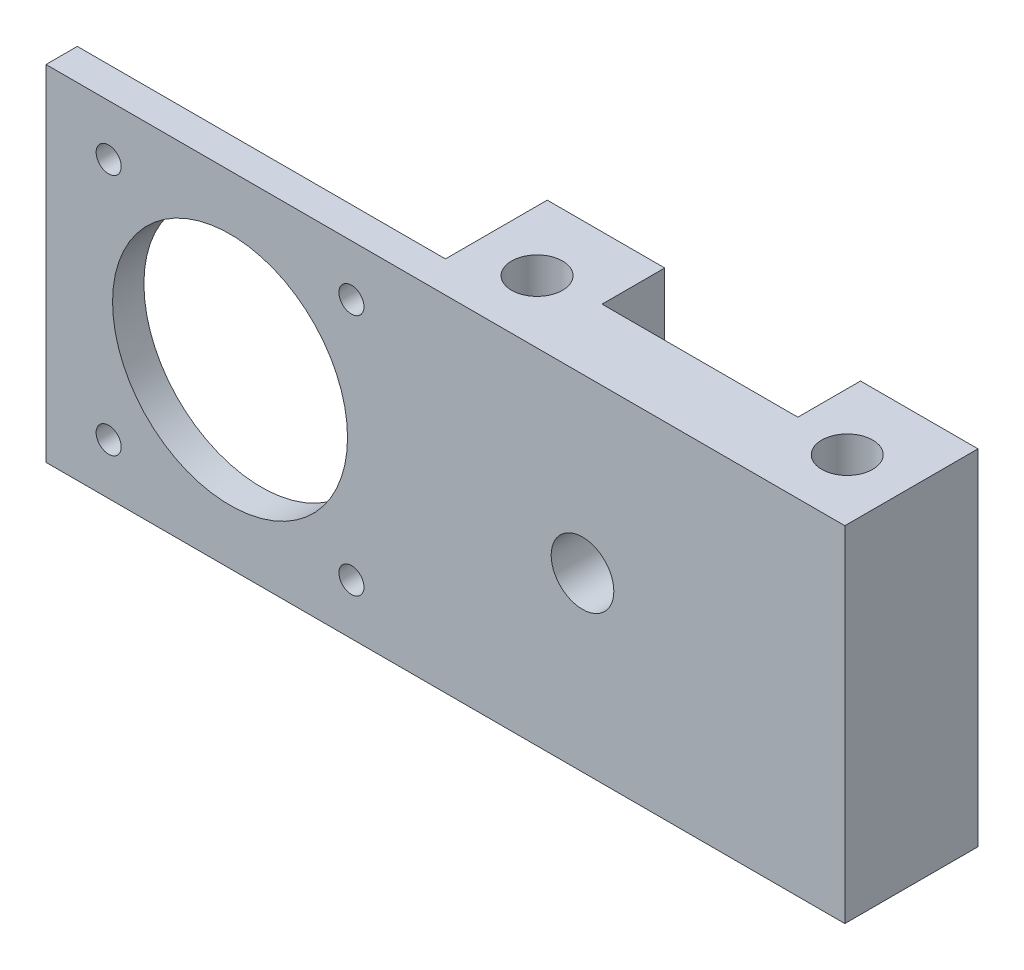
from build123d import *

# Parameters (mm, degrees)
SKETCH_1_W               = 55
SKETCH_1_H               = 44
EXTRUDE_1_DEPTH          = 18
SKETCH_2_R               = 4
CUT_EXTRUDE_1_DEPTH      = 18
HOLE_WIZARD_6_5_6_5_1_D  = 6.5
SKETCH_5_W               = 25
SKETCH_5_H               = 50
CUT_EXTRUDE_2_DEPTH      = 8
SKETCH_6_W               = 47
SKETCH_6_H               = 44
SKETCH_6_R               = 15
EXTRUDE_2_DEPTH          = 5
HOLE_WIZARD_3_2_3_2_1_D  = 3.2
PATTERN_CIRCULAR_1_COUNT = 4
SKETCH_9_W               = 200
SKETCH_9_H               = 100
CUT_EXTRUDE_3_DEPTH      = 1


with BuildPart() as part:
    # Эскиз1 → Бобышка-Вытянуть1 (new body)
    with BuildSketch(Plane.XY):
        Rectangle(SKETCH_1_W, SKETCH_1_H)
    extrude(amount=EXTRUDE_1_DEPTH)

    # Эскиз2 → Вырез-Вытянуть1 (cut)
    with BuildSketch(Plane.XY.offset(18)):
        with Locations((-6, 0)):
            Circle(SKETCH_2_R)
    extrude(amount=-CUT_EXTRUDE_1_DEPTH, mode=Mode.SUBTRACT)

    # Диаметр отверстия Ø6.5 (6.5)1 (through all)
    with Locations(Plane(origin=(0, 22, 0), x_dir=(1, 0, 0), z_dir=(0, 1, 0))):
        with Locations((19.8, -9), (-19.8, -9)):
            Hole(HOLE_WIZARD_6_5_6_5_1_D / 2)

    # Эскиз5 → Вырез-Вытянуть2 (cut)
    with BuildSketch(Plane(origin=(0, 0, 0), x_dir=(-1, 0, 0), z_dir=(0, 0, -1))):
        Rectangle(SKETCH_5_W, SKETCH_5_H)
    extrude(amount=-CUT_EXTRUDE_2_DEPTH, mode=Mode.SUBTRACT)

    # Эскиз6 → Бобышка-Вытянуть2 (add)
    with BuildSketch(Plane.XY.offset(18)):
        with Locations((-51, 0)):
            Rectangle(SKETCH_6_W, SKETCH_6_H)
        with Locations((-51, 0)):
            Circle(SKETCH_6_R, mode=Mode.SUBTRACT)
    extrude(amount=-EXTRUDE_2_DEPTH)

    # Диаметр отверстия Ø3.2 (3.2)1 (through all)
    with Locations(Plane(origin=(0, 0, 13), x_dir=(-1, 0, 0), z_dir=(0, 0, -1))):
        with Locations((35.5, -15.5)):
            hole_wizard_3_2_3_2_1 = Hole(HOLE_WIZARD_3_2_3_2_1_D / 2)

    # Круговой массив1: Диаметр отверстия Ø3.2 (3.2)1 ×4 about axis
    pattern_circular_1_axis = Axis((-51, 0, 0), (0, 0, 1))
    for i in range(1, PATTERN_CIRCULAR_1_COUNT):
        add(hole_wizard_3_2_3_2_1.rotate(pattern_circular_1_axis, i * 360 / PATTERN_CIRCULAR_1_COUNT), mode=Mode.SUBTRACT)

    # Эскиз9 → Вырез-Вытянуть3 (cut)
    with BuildSketch(Plane.XY.offset(18)):
        Rectangle(SKETCH_9_W, SKETCH_9_H)
    extrude(amount=-CUT_EXTRUDE_3_DEPTH, mode=Mode.SUBTRACT)


solid = part.part
